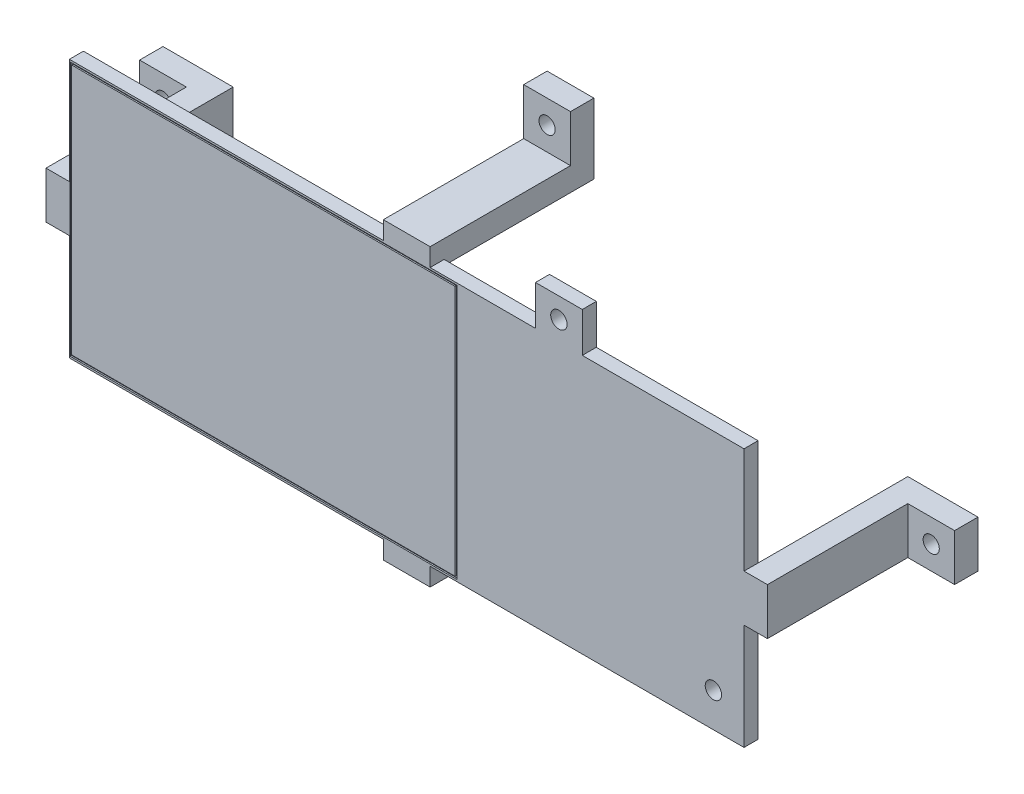
from build123d import *

# Parameters (mm, degrees)
SKETCH2_W             = 5
SKETCH2_H             = 10
BOSS_EXTRUDE1_DEPTH   = 32
SKETCH2_W_2           = 10
SKETCH2_H_2           = 5
BOSS_EXTRUDE1_2_DEPTH = 32
BOSS_EXTRUDE1_3_DEPTH = 32
BOSS_EXTRUDE1_4_DEPTH = 32
SKETCH3_W             = 165
SKETCH3_H             = 55.28
BOSS_EXTRUDE2_DEPTH   = 3
SKETCH4_W             = 10
SKETCH4_H             = 3.86
BOSS_EXTRUDE3_DEPTH   = 3
SKETCH5_W             = 10
SKETCH5_H             = 5
BOSS_EXTRUDE4_DEPTH   = 10
SKETCH7_W             = 5
SKETCH7_H             = 10
BOSS_EXTRUDE5_DEPTH   = 10
SKETCH8_R             = 1.73
CUT_EXTRUDE1_DEPTH    = 6
SKETCH10_W            = 10
SKETCH10_H            = 8.5
SKETCH10_W_2          = 1.85
SKETCH10_H_2          = 10
BOSS_EXTRUDE6_DEPTH   = 3
SKETCH11_R            = 1.75
CUT_EXTRUDE3_DEPTH    = 36
SKETCH12_W            = 82.72
SKETCH12_H            = 54.46
SKETCH12_W_2          = 81.92
SKETCH12_H_2          = 53.66
CUT_EXTRUDE4_DEPTH    = 0.28
CUT_EXTRUDE5_DEPTH    = 4


with BuildPart() as part:
    # Sketch2 → Boss-Extrude1 (new body)
    with BuildSketch(Plane.XY):
        with Locations((-74.585, 0)):
            Rectangle(SKETCH2_W, SKETCH2_H)
    extrude(amount=BOSS_EXTRUDE1_DEPTH)



with BuildPart() as body_2:
    # Sketch2 → Boss-Extrude1 2 (new body)
    with BuildSketch(Plane.XY):
        with Locations((0, 29)):
            Rectangle(SKETCH2_W_2, SKETCH2_H_2)
    extrude(amount=BOSS_EXTRUDE1_2_DEPTH)


with BuildPart() as body_3:
    # Sketch2 → Boss-Extrude1 3 (new body)
    with BuildSketch(Plane.XY):
        with Locations((74.585, 0)):
            Rectangle(SKETCH2_W, SKETCH2_H)
    extrude(amount=BOSS_EXTRUDE1_3_DEPTH)


with BuildPart() as body_4:
    # Sketch2 → Boss-Extrude1 4 (new body)
    with BuildSketch(Plane.XY):
        with Locations((0, -29)):
            Rectangle(SKETCH2_W_2, SKETCH2_H_2)
    extrude(amount=BOSS_EXTRUDE1_4_DEPTH)


with BuildPart() as part_1:
    add(part.part)

    add(body_2.part)  # Boss-Extrude2 merges body 2

    add(body_3.part)  # Boss-Extrude2 merges body 3

    add(body_4.part)  # Boss-Extrude2 merges body 4
    # Sketch3 → Boss-Extrude2 (add)
    with BuildSketch(Plane.XY.offset(32)):
        Rectangle(SKETCH3_W, SKETCH3_H)
    extrude(amount=BOSS_EXTRUDE2_DEPTH)

    # Sketch4 → Boss-Extrude3 (add)
    with BuildSketch(Plane.XY.offset(32)):
        with Locations((0, 29.57)):
            Rectangle(SKETCH4_W, SKETCH4_H)
        with Locations((0, -29.57)):
            Rectangle(SKETCH4_W, SKETCH4_H)
    extrude(amount=BOSS_EXTRUDE3_DEPTH)

    # Sketch5 → Boss-Extrude4 (add)
    with BuildSketch(Plane(origin=(0, 5, 0), x_dir=(1, 0, 0), z_dir=(0, 1, 0))):
        with Locations((-82.085, -2.5)):
            Rectangle(SKETCH5_W, SKETCH5_H)
        with Locations((82.085, -2.5)):
            Rectangle(SKETCH5_W, SKETCH5_H)
    extrude(amount=-BOSS_EXTRUDE4_DEPTH)

    # Sketch7 → Boss-Extrude5 (add)
    with BuildSketch(Plane.ZY.offset(5)):
        with Locations((2.5, 36.5)):
            Rectangle(SKETCH7_W, SKETCH7_H)
        with Locations((2.5, -36.5)):
            Rectangle(SKETCH7_W, SKETCH7_H)
    extrude(amount=-BOSS_EXTRUDE5_DEPTH)

    # Sketch8 → Cut-Extrude1 (cut, through all)
    with BuildSketch(Plane.XY.offset(5)):
        with Locations((-82.085, 0)):
            Circle(SKETCH8_R)
        with Locations((0, -36.5)):
            Circle(SKETCH8_R)
        with Locations((82.085, 0)):
            Circle(SKETCH8_R)
        with Locations((0, 36.5)):
            Circle(SKETCH8_R)
    extrude(amount=-CUT_EXTRUDE1_DEPTH, mode=Mode.SUBTRACT)

    # Sketch10 → Boss-Extrude6 (add)
    with BuildSketch(Plane.XY.offset(35)):
        with Locations((32.52, 31.89)):
            Rectangle(SKETCH10_W, SKETCH10_H)
        with Locations((69.005, -20.32)):
            Rectangle(SKETCH10_W_2, SKETCH10_H_2)
    extrude(amount=-BOSS_EXTRUDE6_DEPTH)

    # Sketch11 → Cut-Extrude3 (cut, through all)
    with BuildSketch(Plane.XY.offset(35)):
        with Locations((32.52, 31.75)):
            Circle(SKETCH11_R)
        with Locations((65.54, -20.32)):
            Circle(SKETCH11_R)
    extrude(amount=-CUT_EXTRUDE3_DEPTH, mode=Mode.SUBTRACT)

    # Sketch12 → Cut-Extrude4 (cut)
    with BuildSketch(Plane.XY.offset(35)):
        with Locations((-30.625, 0)):
            Rectangle(SKETCH12_W, SKETCH12_H)
        with Locations((-30.625, 0)):
            Rectangle(SKETCH12_W_2, SKETCH12_H_2, mode=Mode.SUBTRACT)
    extrude(amount=-CUT_EXTRUDE4_DEPTH, mode=Mode.SUBTRACT)

    # Sketch13 → Cut-Extrude5 (cut, through all)
    with BuildSketch(Plane(origin=(0, 0, 32), x_dir=(-1, 0, 0), z_dir=(0, 0, -1))):
        Polygon((82.5, -27.64), (82.5, 27.64), (72.085, 27.64), (72.085, 5), (77.085, 5), (77.085, -5), (72.085, -5), (72.085, -27.64), align=None)
        Polygon((-82.5, 27.64), (-82.5, -27.64), (-72.085, -27.64), (-72.085, -5), (-77.085, -5), (-77.085, 5), (-72.085, 5), (-72.085, 27.64), align=None)
    extrude(amount=-CUT_EXTRUDE5_DEPTH, mode=Mode.SUBTRACT)


solid = part_1.part
